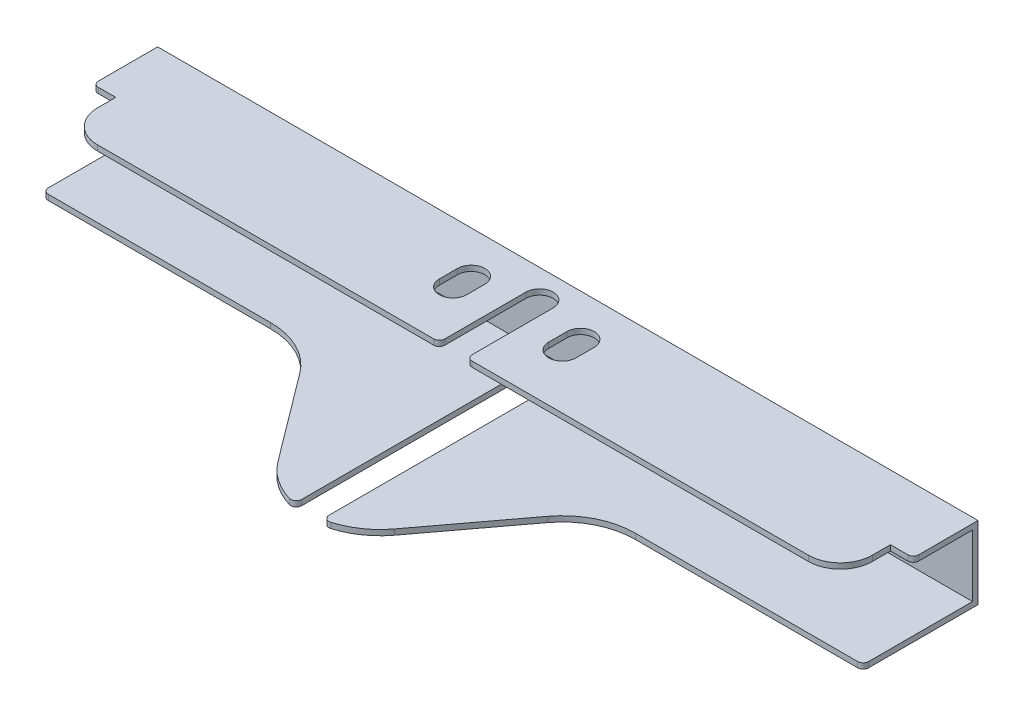
from build123d import *

# Parameters (mm, degrees)
SKETCH1_W           = 90
SKETCH1_H           = 8
BOSS_EXTRUDE1_DEPTH = 12.6
SKETCH2_W           = 90
SKETCH2_H           = 6.8
CUT_EXTRUDE1_DEPTH  = 12
BOSS_EXTRUDE2_DEPTH = 0.6
CUT_EXTRUDE2_DEPTH  = 9
CUT_EXTRUDE4_DEPTH  = 0.6
CUT_EXTRUDE5_DEPTH  = 0.6
FILLET1_R           = 0.6


with BuildPart() as part:
    # Sketch1 → Boss-Extrude1 (new body)
    with BuildSketch(Plane.XY):
        Rectangle(SKETCH1_W, SKETCH1_H)
    extrude(amount=BOSS_EXTRUDE1_DEPTH)

    # Sketch2 → Cut-Extrude1 (cut)
    with BuildSketch(Plane.XY.offset(12.6)):
        Rectangle(SKETCH2_W, SKETCH2_H)
    extrude(amount=-CUT_EXTRUDE1_DEPTH, mode=Mode.SUBTRACT)

    # Sketch8 → Boss-Extrude2 (add)
    with BuildSketch(Plane.XZ.offset(4)):
        with BuildLine():
            Line((6.4, 25.4), (13.6, 15.8))
            ThreePointArc((13.6, 15.8), (16.422291236, 13.444582472), (20, 12.6))
            Line((20, 12.6), (-20, 12.6))
            ThreePointArc((-20, 12.6), (-16.422291236, 13.444582472), (-13.6, 15.8))
            Line((-13.6, 15.8), (-6.4, 25.4))
            ThreePointArc((-6.4, 25.4), (0, 28.6), (6.4, 25.4))
        make_face()
    extrude(amount=-BOSS_EXTRUDE2_DEPTH)

    # Sketch4 → Cut-Extrude2 (cut, through all)
    with BuildSketch(Plane(origin=(0, 4, 0), x_dir=(1, 0, 0), z_dir=(0, 1, 0))):
        with BuildLine():
            Line((-1.5, -3.1), (-1.5, -32.05439328))
            Line((-1.5, -32.05439328), (1.5, -32.05439328))
            Line((1.5, -32.05439328), (1.5, -3.1))
            ThreePointArc((1.5, -3.1), (0, -1.6), (-1.5, -3.1))
        make_face()
    extrude(amount=-CUT_EXTRUDE2_DEPTH, mode=Mode.SUBTRACT)

    # Sketch6 → Cut-Extrude4 (cut)
    with BuildSketch(Plane(origin=(0, 4, 0), x_dir=(1, 0, 0), z_dir=(0, 1, 0))):
        with BuildLine():
            Line((-42.5, -9.1), (-42.5, -7.1))
            Line((-42.5, -7.1), (-45, -7.1))
            Line((-45, -7.1), (-45, -12.6))
            Line((-45, -12.6), (-39, -12.6))
            ThreePointArc((-39, -12.6), (-41.474873734, -11.574873734), (-42.5, -9.1))
        make_face()
    cut_extrude4 = extrude(amount=-CUT_EXTRUDE4_DEPTH, mode=Mode.SUBTRACT)

    # Mirror1: Cut-Extrude4 across plane
    add(cut_extrude4.mirror(Plane(origin=(0, 0, 0), x_dir=(0, 0, 1), z_dir=(1, 0, 0))), mode=Mode.SUBTRACT)

    # Sketch7 → Cut-Extrude5 (cut)
    with BuildSketch(Plane(origin=(0, 4, 0), x_dir=(1, 0, 0), z_dir=(0, 1, 0))):
        with BuildLine():
            Line((-4.5, -4.6), (-4.5, -6.6))
            ThreePointArc((-4.5, -6.6), (-6, -8.1), (-7.5, -6.6))
            Line((-7.5, -6.6), (-7.5, -4.6))
            ThreePointArc((-7.5, -4.6), (-6, -3.1), (-4.5, -4.6))
        make_face()
    cut_extrude5 = extrude(amount=-CUT_EXTRUDE5_DEPTH, mode=Mode.SUBTRACT)

    # Mirror2: Cut-Extrude5 across plane
    add(cut_extrude5.mirror(Plane(origin=(0, 0, 0), x_dir=(0, 0, 1), z_dir=(1, 0, 0))), mode=Mode.SUBTRACT)

    # Fillet1
    fillet1_edges = [part.edges().sort_by_distance(p)[0] for p in [
        (45, -3.7, 12.6),
        (-45, -3.7, 12.6),
        (-1.5, -3.7, 28.458116823),
        (1.5, -3.7, 28.458116823),
        (1.5, 3.7, 12.6),
        (-1.5, 3.7, 12.6),
        (-45, 3.7, 7.1),
        (45, 3.7, 7.1),
    ]]
    fillet(fillet1_edges, radius=FILLET1_R)


solid = part.part
